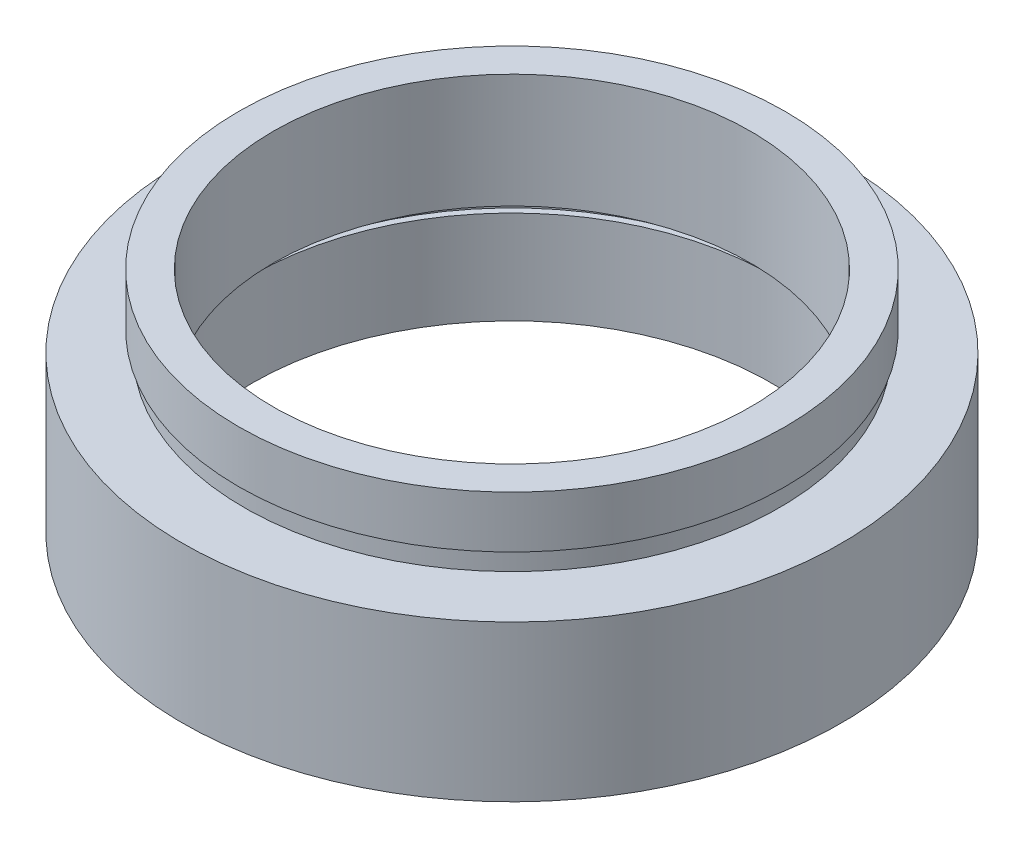
from build123d import *


with BuildPart() as part:
    # 草图1 → 旋转1 (revolve)
    with BuildSketch(Plane.XY, mode=Mode.PRIVATE) as revolve_1_sk:
        Polygon((12.5, 0), (12.5, 4.5), (12.8, 4.5), (12.8, 5.5), (11.5, 5.5), (11.5, 11), (13.16, 11), (13.16, 8.5), (12.9, 8.5), (12.9, 7.5), (15.875, 7.5), (15.875, 0), align=None)
    revolve(revolve_1_sk.sketch.rotate(Axis((0, 16.886018237, 0), (0, -1, 0)), 180), axis=Axis((0, 16.886018237, 0), (0, -1, 0)))  # turned: the seam where the file's is


solid = part.part
